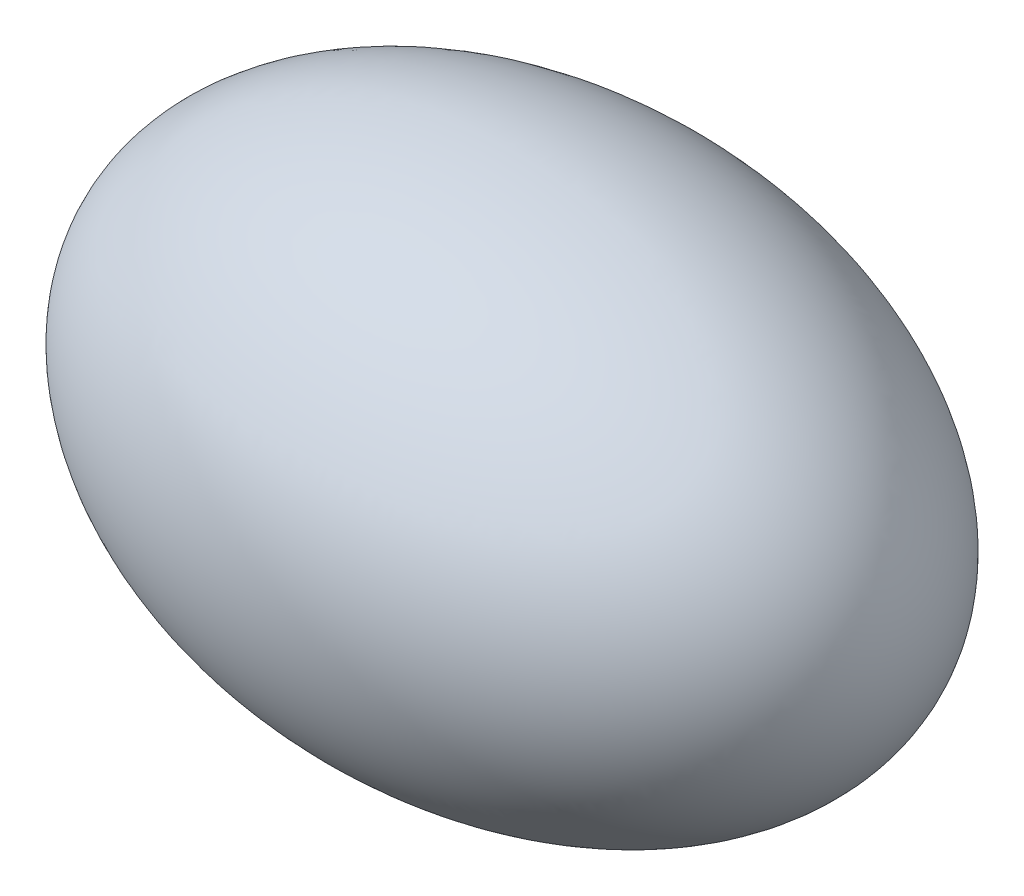
from build123d import *


with BuildPart() as part:
    # Эскиз5 → Повернуть1 (revolve)
    with BuildSketch(Plane(origin=(0, 0, 0), x_dir=(1, 0, 0), z_dir=(0, 1, 0))):
        with BuildLine():
            Line((-814.6818109, -7.987670139), (685.3181891, -7.987670139))
            add(Edge.make_bspline(
                [(685.3181891, -7.987670139), (685.3181891, 492.012329861), (-64.6818109, 492.012329861), (-814.6818109, 492.012329861), (-814.6818109, -7.987670139)],
                knots=[0, 0, 0, 1.570796327, 1.570796327, 3.141592654, 3.141592654, 3.141592654], degree=2, weights=[1, 0.707106781, 1, 0.707106781, 1]))
        make_face()
    revolve(axis=Axis((-814.6818109, 0, 7.987670139), (1, 0, 0)))


solid = part.part
